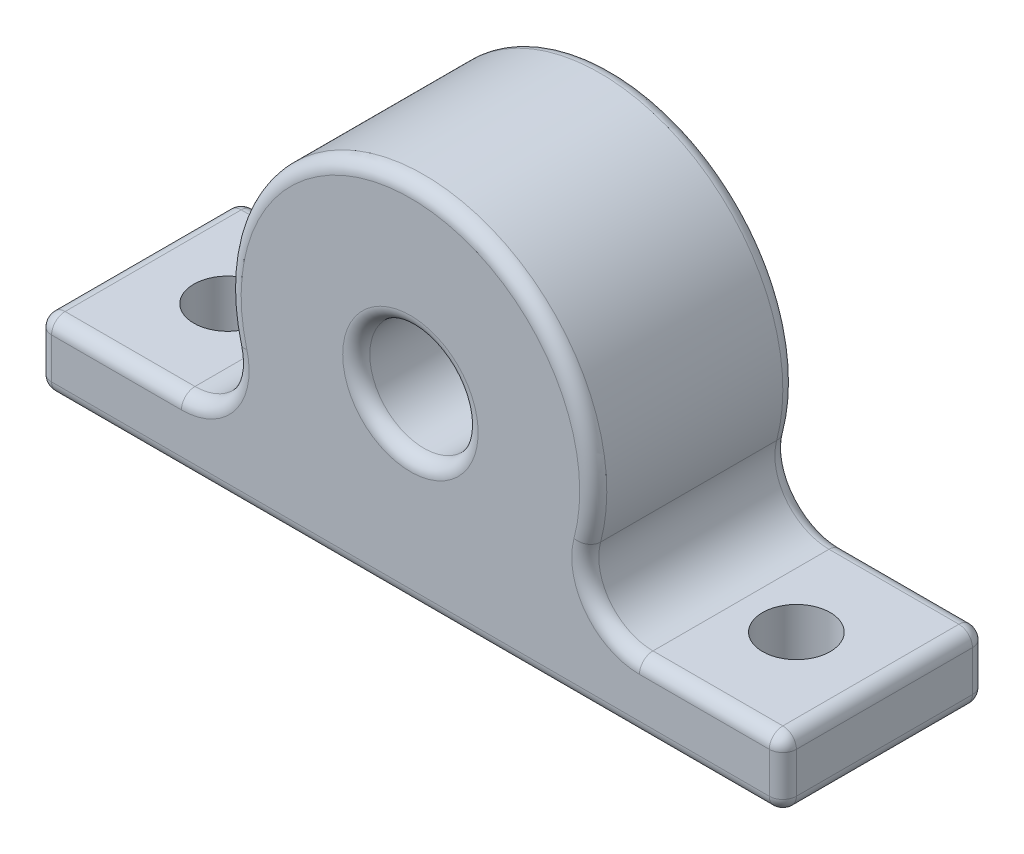
from build123d import *

# Parameters (mm, degrees)
SCHIZZO1_W                               = 55
SCHIZZO1_H                               = 15
ESTRUSIONE_ESTRUSIONE1_DEPTH             = 5
ESTRUSIONE_ESTRUSIONE2_REACH             = 9.5
SCHIZZO2_R                               = 13.5
SCHIZZO2_R_2                             = 4
ESTRUSIONE_ESTRUSIONE2_DIRECTION_2_REACH = 9.5
RACCORDO1_R                              = 4
RACCORDO2_R                              = 1
SCHIZZO3_R                               = 2.5
TAGLIO_ESTRUSIONE1_DEPTH                 = 28


with BuildPart() as part:
    # Schizzo1 → Estrusione-Estrusione1 (new body)
    with BuildSketch(Plane(origin=(0, 0, 0), x_dir=(1, 0, 0), z_dir=(0, 1, 0))):
        Rectangle(SCHIZZO1_W, SCHIZZO1_H)
    extrude(amount=ESTRUSIONE_ESTRUSIONE1_DEPTH)

    # Estrusione-Estrusione2: up to this face of the body (flat: up to its plane)
    estrusione_estrusione2_end = Plane(part.part.faces().sort_by_distance((0, 2.5, 7.5))[0])
    # Schizzo2 → Estrusione-Estrusione2 (add, up to the picked face)
    with BuildSketch(Plane.XY, mode=Mode.PRIVATE) as estrusione_estrusione2_sk1:
        with Locations((0, 13.5)):
            Circle(SCHIZZO2_R)
        with Locations((0, 13.5)):
            Circle(SCHIZZO2_R_2, mode=Mode.SUBTRACT)
    estrusione_estrusione2_tool1 = split(extrude(estrusione_estrusione2_sk1.sketch, amount=ESTRUSIONE_ESTRUSIONE2_REACH, mode=Mode.PRIVATE), bisect_by=estrusione_estrusione2_end, keep=Keep.BOTH, mode=Mode.PRIVATE)
    add(estrusione_estrusione2_tool1.solids().sort_by_distance((-13.118162, 13.5, 0))[0])

    # Estrusione-Estrusione2 direction 2: up to this face of the body (flat: up to its plane)
    estrusione_estrusione2_direction_2_end = Plane(part.part.faces().sort_by_distance((0, 2.5, -7.5))[0])
    # Schizzo2 → Estrusione-Estrusione2 direction 2 (add, up to the picked face)
    with BuildSketch(Plane.XY, mode=Mode.PRIVATE) as estrusione_estrusione2_direction_2_sk1:
        with Locations((0, 13.5)):
            Circle(SCHIZZO2_R)
        with Locations((0, 13.5)):
            Circle(SCHIZZO2_R_2, mode=Mode.SUBTRACT)
    estrusione_estrusione2_direction_2_tool1 = split(extrude(estrusione_estrusione2_direction_2_sk1.sketch, amount=-ESTRUSIONE_ESTRUSIONE2_DIRECTION_2_REACH, mode=Mode.PRIVATE), bisect_by=estrusione_estrusione2_direction_2_end, keep=Keep.BOTH, mode=Mode.PRIVATE)
    add(estrusione_estrusione2_direction_2_tool1.solids().sort_by_distance((-13.118162, 13.5, 0))[0])

    # Raccordo1
    raccordo1_edges = [part.edges().sort_by_distance(p)[0] for p in [
        (10.488088482, 5, 0),
        (-10.488088482, 5, 0),
    ]]
    fillet(raccordo1_edges, radius=RACCORDO1_R)

    # Raccordo2
    raccordo2_edges = [part.edges().sort_by_distance(p)[0] for p in [
        (-27.5, 5, 0),
        (-22.205767263, 5, 7.5),
        (-4, 13.5, -7.5),
        (-4, 13.5, 7.5),
        (22.205767263, 5, 7.5),
        (0, 27, -7.5),
        (0, 27, 7.5),
        (-22.205767263, 5, -7.5),
        (13.740234657, 6.562202399, 7.5),
        (13.740234657, 6.562202399, -7.5),
        (-13.740234657, 6.562202399, -7.5),
        (-13.740234657, 6.562202399, 7.5),
        (27.5, 5, 0),
        (0, 0, 7.5),
        (-27.5, 0, 0),
        (0, 0, -7.5),
        (27.5, 0, 0),
        (27.5, 2.5, 7.5),
        (-27.5, 2.5, 7.5),
        (-27.5, 2.5, -7.5),
        (27.5, 2.5, -7.5),
        (22.205767263, 5, -7.5),
    ]]
    fillet(raccordo2_edges, radius=RACCORDO2_R)

    # Schizzo3 → Taglio-Estrusione1 (cut, through all)
    with BuildSketch(Plane(origin=(0, 0, 0), x_dir=(1, 0, 0), z_dir=(0, 1, 0))):
        with Locations((21, 0)):
            Circle(SCHIZZO3_R)
        with Locations((-21, 0)):
            Circle(SCHIZZO3_R)
    extrude(amount=TAGLIO_ESTRUSIONE1_DEPTH, mode=Mode.SUBTRACT)


solid = part.part
